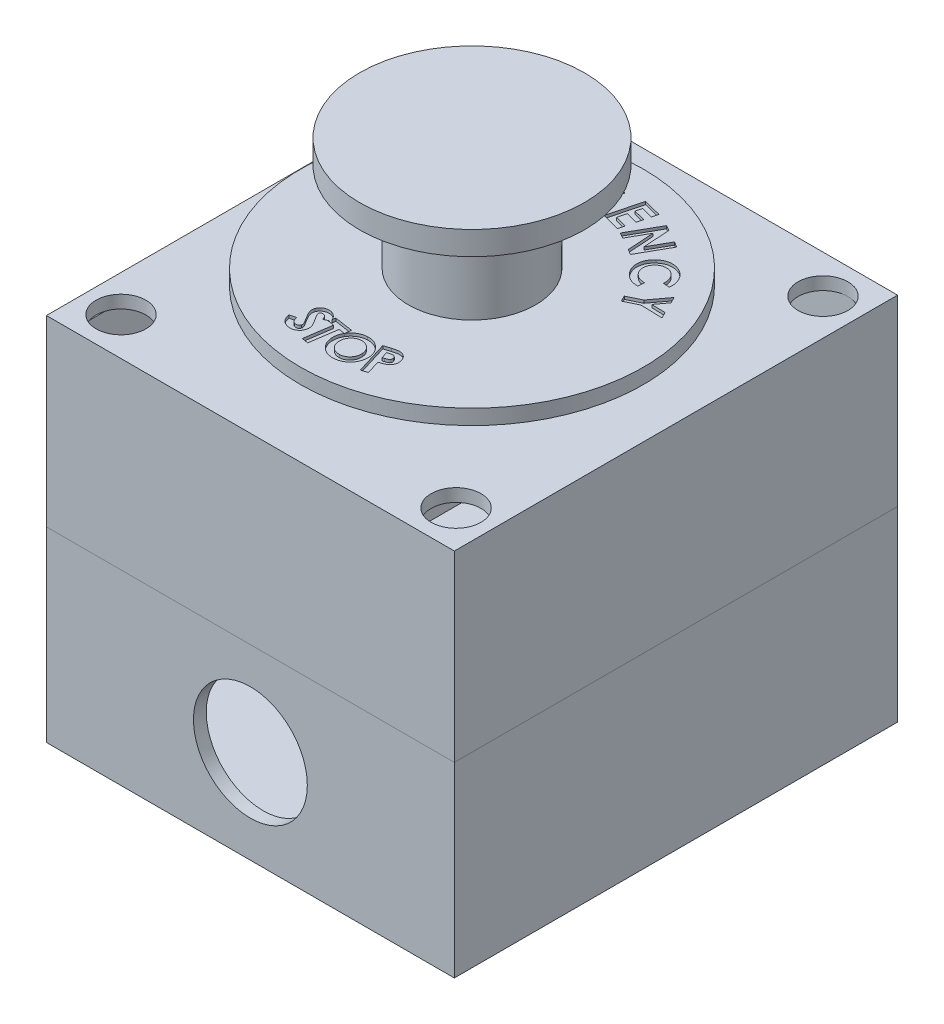
from build123d import *

# Parameters (mm, degrees)
SKETCH1_W           = 71.65
SKETCH1_H           = 77.85
BOSS_EXTRUDE1_DEPTH = 32.8
SHELL3_T            = -2.25
SKETCH2_W           = 71.65
SKETCH2_H           = 77.85
BOSS_EXTRUDE2_DEPTH = 32.15
SHELL4_T            = -2.25
SKETCH3_R           = 11.175
SKETCH3_R_2         = 4.375
CUT_EXTRUDE1_DEPTH  = 2.25
SKETCH4_R           = 30.125
SKETCH4_R_2         = 11.175
BOSS_EXTRUDE3_DEPTH = 2.65
CUT_EXTRUDE2_DEPTH  = 0.5
SKETCH6_R           = 11.175
BOSS_EXTRUDE4_DEPTH = 21.35
SKETCH7_R           = 19.75
BOSS_EXTRUDE5_DEPTH = 4.15
SKETCH8_R           = 10
CUT_EXTRUDE3_DEPTH  = 2.25


with BuildPart() as part:
    # Sketch1 → Boss-Extrude1 (new body)
    with BuildSketch(Plane(origin=(0, 0, 0), x_dir=(1, 0, 0), z_dir=(0, 1, 0))):
        Rectangle(SKETCH1_W, SKETCH1_H)
    extrude(amount=BOSS_EXTRUDE1_DEPTH)

    # Shell3
    shell3_openings = [part.faces().sort_by_distance(p)[0] for p in [
        (0, 32.8, 0),
    ]]
    offset(amount=SHELL3_T, openings=shell3_openings, kind=Kind.INTERSECTION)

    # Sketch8 → Cut-Extrude3 (cut)
    with BuildSketch(Plane.XY.offset(38.925)):
        with Locations((0, 16.4)):
            Circle(SKETCH8_R)
    extrude(amount=-CUT_EXTRUDE3_DEPTH, mode=Mode.SUBTRACT)


with BuildPart() as body_2:
    # Sketch2 → Boss-Extrude2 (new body)
    with BuildSketch(Plane(origin=(0, 32.8, 0), x_dir=(1, 0, 0), z_dir=(0, 1, 0))):
        Rectangle(SKETCH2_W, SKETCH2_H)
    extrude(amount=BOSS_EXTRUDE2_DEPTH)

    # Shell4
    shell4_openings = [body_2.faces().sort_by_distance(p)[0] for p in [
        (0, 32.8, 0),
    ]]
    offset(amount=SHELL4_T, openings=shell4_openings, kind=Kind.INTERSECTION)

    # Sketch3 → Cut-Extrude1 (cut)
    with BuildSketch(Plane(origin=(0, 64.95, 0), x_dir=(1, 0, 0), z_dir=(0, 1, 0))):
        with Locations(Location((0, 0, 0), (0, 0, 270))):
            Circle(SKETCH3_R)
        with Locations(Location((-29.425, 32.225, 0), (0, 0, 270))):
            Circle(SKETCH3_R_2)
        with Locations(Location((29.425, 32.225, 0), (0, 0, 270))):
            Circle(SKETCH3_R_2)
        with Locations(Location((29.425, -32.225, 0), (0, 0, 270))):
            Circle(SKETCH3_R_2)
        with Locations(Location((-29.425, -32.225, 0), (0, 0, 270))):
            Circle(SKETCH3_R_2)
    extrude(amount=-CUT_EXTRUDE1_DEPTH, mode=Mode.SUBTRACT)


with BuildPart() as body_3:
    # Sketch4 → Boss-Extrude3 (new body)
    with BuildSketch(Plane(origin=(0, 67.95, 0), x_dir=(1, 0, 0), z_dir=(0, 1, 0))):
        with Locations(Location((0, 0, 0), (0, 0, 270))):
            Circle(SKETCH4_R)
        with Locations(Location((0, 0, 0), (0, 0, 270))):
            Circle(SKETCH4_R_2, mode=Mode.SUBTRACT)
    extrude(amount=BOSS_EXTRUDE3_DEPTH)

    # Sketch5 → Cut-Extrude2 (cut)
    with BuildSketch(Plane(origin=(0, 70.6, 0), x_dir=(1, 0, 0), z_dir=(0, 1, 0))):
        Polygon((22.216736473, 13.295451936), (22.74678455, 12.19929809), (21.305678781, 10.270211551), (23.708323012, 10.210115397), (24.232361473, 9.127182705), (20.436688396, 9.225740397), (18.115774935, 8.103144243), (17.618178781, 9.130788474), (19.939092242, 10.253384628), align=None)
        with BuildLine():
            Line((20.220089869, 14.442296373), (19.121532177, 14.51921945))
            add(Edge.make_bspline(
                [(19.121532177, 14.51921945), (19.126635475, 14.615363019), (19.136592085, 14.802940543), (19.119361217, 15.078907871), (19.082129696, 15.341473275), (19.019601875, 15.591110902), (18.931427635, 15.826880028), (18.818536734, 16.048742483), (18.684399386, 16.259601178), (18.575486958, 16.385850104), (18.520570638, 16.449507911)],
                knots=[0, 0, 0, 0, 1.109559889, 2.164767739, 3.182852736, 4.164553532, 5.126637444, 6.07925455, 7.031512999, 8, 8, 8, 8], degree=3))
            add(Edge.make_bspline(
                [(18.520570638, 16.449507911), (18.471774653, 16.500108571), (18.375772324, 16.599661454), (18.218766209, 16.730949825), (18.054176946, 16.843691895), (17.881738472, 16.938325929), (17.700442301, 17.012544472), (17.511867375, 17.069964204), (17.315119658, 17.106514609), (17.113183165, 17.125829206), (16.910340069, 17.125856503), (16.710994634, 17.106916417), (16.518294194, 17.068005488), (16.330775871, 17.011809359), (16.150903719, 16.932830126), (15.976489909, 16.835590979), (15.807303581, 16.720806029), (15.703179532, 16.630113425), (15.650378331, 16.584123296)],
                knots=[0, 0, 0, 0, 1.052386963, 2.070489961, 3.059233594, 4.036767781, 5.010814159, 5.988569374, 6.98430004, 8.003039573, 9.023245161, 10.018089293, 10.997298366, 11.963567616, 12.94463228, 13.933211989, 14.951933846, 16, 16, 16, 16], degree=3))
            add(Edge.make_bspline(
                [(15.650378331, 16.584123296), (15.614772459, 16.550425515), (15.544161636, 16.48359867), (15.445533012, 16.37822406), (15.356762591, 16.268418899), (15.275705446, 16.156333236), (15.203039547, 16.041089621), (15.141306104, 15.921366187), (15.084864918, 15.800127811), (15.025165629, 15.634301379), (14.970140452, 15.422782004), (14.941211111, 15.162987386), (14.948496459, 14.900051837), (14.985648234, 14.681111095), (15.033805663, 14.508514966), (15.076445502, 14.380285781), (15.130089667, 14.256180426), (15.191648478, 14.134883873), (15.259876546, 14.015622412), (15.336971929, 13.899670568), (15.423978312, 13.788103053), (15.486573787, 13.716444458), (15.518166792, 13.680277142)],
                knots=[0, 0, 0, 0, 0.902655461, 1.790076806, 2.655418219, 3.501067431, 4.336289324, 5.161315006, 5.98011549, 6.797019175, 8.40390207, 9.992644644, 11.594234471, 13.232865513, 14.066946146, 14.89286202, 15.719206162, 16.553971738, 17.396784059, 18.248014752, 19.115743145, 20, 20, 20, 20], degree=3))
            add(Edge.make_bspline(
                [(15.518166792, 13.680277142), (15.574188779, 13.62162849), (15.684376753, 13.506274207), (15.868969892, 13.359092288), (16.060742087, 13.232056184), (16.231202828, 13.146752199), (16.375485639, 13.09057285), (16.492558234, 13.05384902), (16.617877505, 13.019708676), (16.75199737, 12.991510765), (16.894702439, 12.96715361), (17.046378113, 12.948606422), (17.206634234, 12.932518405), (17.316612751, 12.926259489), (17.3727341, 12.923065604)],
                knots=[0, 0, 0, 0, 1.412694756, 2.778587148, 4.105776388, 5.417860226, 6.092421986, 6.803777457, 7.556138486, 8.356275231, 9.192319846, 10.079560441, 11.020011728, 12, 12, 12, 12], degree=3))
            Line((17.3727341, 12.923065604), (17.299416792, 11.808882911))
            add(Edge.make_bspline(
                [(17.299416792, 11.808882911), (17.224052403, 11.813978196), (17.076727646, 11.823938625), (16.861505837, 11.847171838), (16.656350687, 11.875092153), (16.462405138, 11.912621306), (16.278796331, 11.956069163), (16.105880311, 12.004443997), (15.943858514, 12.061430356), (15.791118571, 12.125213671), (15.64554747, 12.198560491), (15.503496375, 12.279711572), (15.362120689, 12.367603892), (15.226134031, 12.469075351), (15.088899488, 12.57478649), (14.957592311, 12.69407974), (14.826037996, 12.819496243), (14.742108373, 12.90902991), (14.699657177, 12.954315604)],
                knots=[0, 0, 0, 0, 1.237979504, 2.42004258, 3.5474711, 4.630597417, 5.65636662, 6.639570284, 7.572081054, 8.469719187, 9.350749792, 10.241830455, 11.150925216, 12.07693919, 13.021511017, 13.988952338, 14.982821856, 16, 16, 16, 16], degree=3))
            add(Edge.make_bspline(
                [(14.699657177, 12.954315604), (14.62463575, 13.039891469), (14.477320626, 13.207931718), (14.28952194, 13.4784533), (14.129929181, 13.754157822), (14.001661711, 14.036918937), (13.906362221, 14.328049509), (13.84061445, 14.625117568), (13.808858351, 14.929839896), (13.806128317, 15.237829609), (13.834956878, 15.544678583), (13.893833945, 15.844406372), (13.983432231, 16.134366506), (14.102539843, 16.414830196), (14.254631547, 16.683634509), (14.434723817, 16.943513917), (14.645278351, 17.193512489), (14.805528186, 17.34639258), (14.887157177, 17.424267527)],
                knots=[0, 0, 0, 0, 1.087298607, 2.135063766, 3.142275972, 4.129746234, 5.097556959, 6.066004182, 7.032973177, 8.021238017, 9.006112165, 9.974407879, 10.93640254, 11.90257463, 12.881786517, 13.883748322, 14.922011451, 16, 16, 16, 16], degree=3))
            add(Edge.make_bspline(
                [(14.887157177, 17.424267527), (14.942148453, 17.473195034), (15.050803849, 17.569869237), (15.223984018, 17.698406476), (15.397879804, 17.817777497), (15.577288114, 17.921060621), (15.761172292, 18.010155872), (15.947923172, 18.087355124), (16.1392095, 18.150183128), (16.333662234, 18.199142128), (16.530724789, 18.23566275), (16.729620618, 18.25685616), (16.929571347, 18.265711297), (17.130824107, 18.259556693), (17.332750725, 18.238860994), (17.535773388, 18.204710835), (17.739963948, 18.158383515), (17.943484052, 18.096473094), (18.144569506, 18.02416079), (18.339681082, 17.938559644), (18.527115786, 17.841266599), (18.70720638, 17.732244133), (18.880533145, 17.612674935), (19.045014868, 17.479016895), (19.20487234, 17.337098636), (19.302983979, 17.23273649), (19.352301407, 17.180277142)],
                knots=[0, 0, 0, 0, 1.061507876, 2.097397393, 3.109068641, 4.103550453, 5.080796923, 6.0555098, 7.017037681, 7.983020916, 8.946770381, 9.90622827, 10.866660828, 11.832453788, 12.808554109, 13.793090768, 14.80132106, 15.827292257, 16.860468579, 17.882916222, 18.89900383, 19.905243602, 20.918680406, 21.934307502, 22.961645706, 24, 24, 24, 24], degree=3))
            add(Edge.make_bspline(
                [(19.352301407, 17.180277142), (19.392785422, 17.134160342), (19.473563148, 17.042143522), (19.58694232, 16.898048597), (19.690058645, 16.747378541), (19.785280353, 16.591595297), (19.873330556, 16.43120615), (19.951143958, 16.264126326), (20.022604349, 16.092923023), (20.083186535, 15.915965487), (20.136336203, 15.736941354), (20.178462143, 15.555459804), (20.210644534, 15.373286803), (20.234172487, 15.189627869), (20.245578336, 15.004570184), (20.248393268, 14.818024397), (20.239970264, 14.630213437), (20.22673856, 14.505142332), (20.220089869, 14.442296373)],
                knots=[0, 0, 0, 0, 0.994048471, 1.983424239, 2.96821208, 3.950022362, 4.940440777, 5.930518856, 6.934560982, 7.94446007, 8.959061906, 9.958794142, 10.960799264, 11.955038424, 12.95668612, 13.962802997, 14.976345499, 16, 16, 16, 16], degree=3))
        make_face()
        Polygon((10.608315809, 23.562697309), (11.555431193, 23.02784154), (11.849902347, 18.349956924), (13.782594655, 21.767024232), (14.771777347, 21.208130001), (11.834277347, 16.014620386), (10.884758116, 16.551880001), (10.587883116, 21.217745386), (8.659998501, 17.810293463), (7.670815809, 18.369187693), align=None)
        Polygon((5.081720858, 25.415085868), (8.247586243, 24.596576252), (7.968740089, 23.516047406), (5.899028551, 24.052105098), (5.627393935, 23.002826252), (7.697105474, 22.46676856), (7.423067012, 21.405470483), (5.353355474, 21.941528175), (4.957922781, 20.415085868), (7.02763432, 19.879028175), (6.747586243, 18.79489356), (3.581720858, 19.613403175), align=None)
        with BuildLine():
            Line((2.002101237, 24.751845655), (1.225658929, 23.939345655))
            add(Edge.make_bspline(
                [(1.225658929, 23.939345655), (1.160739613, 24.001604367), (1.033255163, 24.123864089), (0.825246849, 24.280759616), (0.611752878, 24.414598564), (0.390255387, 24.522426248), (0.161430287, 24.604826973), (-0.075025273, 24.659516896), (-0.317852068, 24.69253828), (-0.482168717, 24.692812731), (-0.565206456, 24.692951424)],
                knots=[0, 0, 0, 0, 1.078351845, 2.117599175, 3.119307423, 4.097454024, 5.067464779, 6.030507225, 7.004712988, 8, 8, 8, 8], degree=3))
            add(Edge.make_bspline(
                [(-0.565206456, 24.692951424), (-0.637035056, 24.688975864), (-0.778149644, 24.681165471), (-0.98516717, 24.648461385), (-1.182547393, 24.59709373), (-1.370064154, 24.526248765), (-1.549362866, 24.440238789), (-1.71761614, 24.333235115), (-1.877853746, 24.210281339), (-2.024990446, 24.069088447), (-2.158935652, 23.91626784), (-2.276474172, 23.754991109), (-2.374183878, 23.585537788), (-2.454249977, 23.409463561), (-2.514813703, 23.225306863), (-2.555271175, 23.033876998), (-2.577567055, 22.834923752), (-2.577340832, 22.700217486), (-2.577225686, 22.631653348)],
                knots=[0, 0, 0, 0, 1.074817449, 2.111588153, 3.12694921, 4.118071934, 5.103733486, 6.09404167, 7.093075841, 8.118192181, 9.136780168, 10.127468555, 11.096117737, 12.055671245, 13.013953079, 13.987698506, 14.975758707, 16, 16, 16, 16], degree=3))
            add(Edge.make_bspline(
                [(-2.577225686, 22.631653348), (-2.573475283, 22.560989046), (-2.566080931, 22.421666241), (-2.529982031, 22.218127095), (-2.477626758, 22.022386073), (-2.403601117, 21.836271889), (-2.312316866, 21.658092111), (-2.199901649, 21.490498042), (-2.071539082, 21.329336632), (-1.922990832, 21.181124619), (-1.76169303, 21.045391459), (-1.58964326, 20.927739467), (-1.409889664, 20.827698183), (-1.220170805, 20.750031431), (-1.023484881, 20.687802207), (-0.81708956, 20.647372654), (-0.602968248, 20.625380789), (-0.457483815, 20.625555265), (-0.383716071, 20.625643732)],
                knots=[0, 0, 0, 0, 1.024221376, 2.019370362, 2.988020267, 3.954738387, 4.915146988, 5.882544282, 6.873215482, 7.895066353, 8.916801852, 9.922907492, 10.909951126, 11.890764485, 12.887519874, 13.89367573, 14.931990273, 16, 16, 16, 16], degree=3))
            add(Edge.make_bspline(
                [(-0.383716071, 20.625643732), (-0.335599675, 20.627900207), (-0.241156795, 20.632329218), (-0.102702126, 20.64818423), (0.029745559, 20.670939954), (0.156480802, 20.700562045), (0.276817628, 20.739339536), (0.391314851, 20.785024592), (0.500203498, 20.83776717), (0.602378002, 20.899453423), (0.699813424, 20.968714755), (0.791682823, 21.046107236), (0.877953227, 21.133033325), (0.959725159, 21.227376636), (1.035009707, 21.332002853), (1.108227089, 21.443110553), (1.172005316, 21.565362421), (1.211554362, 21.649937518), (1.231668544, 21.692951424)],
                knots=[0, 0, 0, 0, 1.120714692, 2.199739221, 3.240504075, 4.246831093, 5.225747871, 6.179704807, 7.113725497, 8.037922487, 8.953757669, 9.893253267, 10.829412051, 11.801243693, 12.795185344, 13.827058911, 14.894867548, 16, 16, 16, 16], degree=3))
            Line((1.231668544, 21.692951424), (-0.49669684, 21.644874501))
            Line((-0.49669684, 21.644874501), (-0.526744917, 22.712182194))
            Line((-0.526744917, 22.712182194), (2.475658929, 22.796316809))
            Line((2.475658929, 22.796316809), (2.491283929, 22.545114886))
            add(Edge.make_bspline(
                [(2.491283929, 22.545114886), (2.491725712, 22.480191545), (2.492604845, 22.350996252), (2.478930803, 22.157820961), (2.452901069, 21.966983575), (2.412365817, 21.778515471), (2.361173768, 21.591950716), (2.29563997, 21.407397538), (2.217725416, 21.225157116), (2.127573072, 21.046887288), (2.028535214, 20.874446966), (1.920566809, 20.710744008), (1.803786315, 20.558006783), (1.679474005, 20.415719691), (1.548142171, 20.28288012), (1.40876859, 20.159874642), (1.260283245, 20.04833566), (1.105260841, 19.94582477), (0.942857074, 19.854068057), (0.772572701, 19.774986163), (0.59577333, 19.70584084), (0.410584126, 19.650093549), (0.219153921, 19.602318661), (0.019300653, 19.569563096), (-0.186915185, 19.54621621), (-0.327165876, 19.539898483), (-0.398139148, 19.536701424)],
                knots=[0, 0, 0, 0, 1.004147739, 1.998220677, 2.993143514, 3.981479951, 4.9785051, 5.984182096, 7.008857228, 8.042807654, 9.073016962, 10.083857123, 11.074387429, 12.045231887, 13.005092057, 13.9625276, 14.91831651, 15.875872428, 16.836132773, 17.801102652, 18.778356565, 19.770437119, 20.791205421, 21.828550206, 22.901146976, 24, 24, 24, 24], degree=3))
            add(Edge.make_bspline(
                [(-0.398139148, 19.536701424), (-0.47468068, 19.535714086), (-0.625890273, 19.533763576), (-0.84978901, 19.548013344), (-1.067461484, 19.572397256), (-1.279396391, 19.611377369), (-1.485296303, 19.662870584), (-1.685877601, 19.726479096), (-1.879559494, 19.803864985), (-2.067168888, 19.892713177), (-2.247578066, 19.993157201), (-2.417919841, 20.106734485), (-2.580395277, 20.229597642), (-2.732795508, 20.364831605), (-2.877492317, 20.509726729), (-3.01104892, 20.667236347), (-3.136197208, 20.834665595), (-3.252678757, 21.011591327), (-3.356323706, 21.197122796), (-3.44797662, 21.387325638), (-3.5267091, 21.581519526), (-3.590969879, 21.780193607), (-3.644953849, 21.982115628), (-3.68235448, 22.188831272), (-3.710345715, 22.39897535), (-3.716139946, 22.541019413), (-3.719052609, 22.612422578)],
                knots=[0, 0, 0, 0, 1.088999131, 2.151343354, 3.190249436, 4.204567505, 5.215418359, 6.208947955, 7.196767941, 8.181209007, 9.161414191, 10.132355917, 11.09252403, 12.057976134, 13.029603973, 14.004238299, 14.994030836, 16.002950311, 17.01638665, 18.016032339, 19.005972659, 19.995830881, 20.986001042, 21.97789331, 22.983520927, 24, 24, 24, 24], degree=3))
            add(Edge.make_bspline(
                [(-3.719052609, 22.612422578), (-3.719213978, 22.709850725), (-3.719532193, 22.901976767), (-3.689497467, 23.185545607), (-3.637252857, 23.460670895), (-3.557551653, 23.726173197), (-3.453034564, 23.982972568), (-3.325484296, 24.231153353), (-3.172828451, 24.470848914), (-3.052674258, 24.619136011), (-2.991889148, 24.694153348)],
                knots=[0, 0, 0, 0, 1.035478945, 2.041940428, 3.027109918, 4.009807164, 4.984556678, 5.971631463, 6.97386349, 8, 8, 8, 8], degree=3))
            add(Edge.make_bspline(
                [(-2.991889148, 24.694153348), (-2.954380824, 24.7379282), (-2.879809177, 24.824958555), (-2.759126755, 24.945507957), (-2.634964243, 25.059206734), (-2.506624703, 25.164795585), (-2.37353562, 25.262843737), (-2.236196987, 25.352889256), (-2.092632063, 25.433453914), (-1.946109791, 25.508380172), (-1.793751194, 25.572626328), (-1.638174516, 25.631286609), (-1.47710511, 25.680286999), (-1.311216211, 25.720657023), (-1.141319505, 25.754844312), (-0.966769566, 25.779872651), (-0.787437802, 25.79672252), (-0.666199936, 25.802040227), (-0.604869917, 25.804730271)],
                knots=[0, 0, 0, 0, 1.017680996, 2.023288138, 3.009898991, 3.99009594, 4.95661266, 5.928011526, 6.888084382, 7.86264738, 8.832550635, 9.806394246, 10.797864034, 11.803446286, 12.820536837, 13.857151809, 14.916007658, 16, 16, 16, 16], degree=3))
            add(Edge.make_bspline(
                [(-0.604869917, 25.804730271), (-0.540361746, 25.805815435), (-0.412486541, 25.807966568), (-0.221906752, 25.799141872), (-0.03424326, 25.780963333), (0.150633784, 25.754488368), (0.333099236, 25.720259237), (0.511680948, 25.673852889), (0.68792714, 25.620158273), (0.802784745, 25.577355984), (0.860274314, 25.555932194)],
                knots=[0, 0, 0, 0, 1.034683742, 2.051064099, 3.058219287, 4.057945443, 5.046078613, 6.034274475, 7.016097248, 8, 8, 8, 8], degree=3))
            add(Edge.make_bspline(
                [(0.860274314, 25.555932194), (0.908634743, 25.535720208), (1.006772592, 25.494704012), (1.150945774, 25.420523039), (1.295187018, 25.336595018), (1.43836837, 25.241343199), (1.580399474, 25.134938009), (1.722644385, 25.018140156), (1.863933016, 24.889859317), (1.955594823, 24.798300045), (2.002101237, 24.751845655)],
                knots=[0, 0, 0, 0, 0.89389203, 1.813975655, 2.763519178, 3.739795132, 4.745905524, 5.789956038, 6.878690904, 8, 8, 8, 8], degree=3))
        make_face()
        with BuildLine():
            Line((-9.813180429, 23.918278999), (-8.674959275, 24.300490537))
            add(Edge.make_bspline(
                [(-8.674959275, 24.300490537), (-8.599773658, 24.325354459), (-8.454776552, 24.373305074), (-8.24348218, 24.43562611), (-8.047186177, 24.487722501), (-7.866531752, 24.52920125), (-7.700331662, 24.557901624), (-7.549672051, 24.578427337), (-7.41342006, 24.585472476), (-7.290446691, 24.58365338), (-7.176165975, 24.571571771), (-7.066815942, 24.549041434), (-6.959349906, 24.521257849), (-6.855360205, 24.481534067), (-6.753322941, 24.435357701), (-6.654201723, 24.378979719), (-6.556863961, 24.315920799), (-6.463493886, 24.243230669), (-6.372767468, 24.164557636), (-6.289244381, 24.076467294), (-6.211015906, 23.982500041), (-6.137777055, 23.882522925), (-6.073705019, 23.773360745), (-6.013241649, 23.658712747), (-5.960354494, 23.536233729), (-5.92973102, 23.451697339), (-5.914141968, 23.408663614)],
                knots=[0, 0, 0, 0, 1.706699695, 3.291407649, 4.74706766, 6.083599819, 7.284612418, 8.38136156, 9.358493001, 10.222167383, 11.029853103, 11.830864387, 12.626833115, 13.419187092, 14.226734324, 15.038609625, 15.874468565, 16.724217417, 17.5868984, 18.460231229, 19.336972531, 20.221334869, 21.127641506, 22.062299829, 23.013602843, 24, 24, 24, 24], degree=3))
            add(Edge.make_bspline(
                [(-5.914141968, 23.408663614), (-5.899413264, 23.363189865), (-5.870483681, 23.27387199), (-5.839851467, 23.138645638), (-5.81761709, 23.006682889), (-5.806571958, 22.877235667), (-5.806747169, 22.751019816), (-5.816342841, 22.6276449), (-5.835377074, 22.5069105), (-5.865298502, 22.388912559), (-5.906978236, 22.274294244), (-5.956979951, 22.162012833), (-6.019248363, 22.053688847), (-6.090295948, 21.947337539), (-6.17204424, 21.843804789), (-6.265484547, 21.744429396), (-6.367258025, 21.646152923), (-6.442091604, 21.585979464), (-6.480247737, 21.55529823)],
                knots=[0, 0, 0, 0, 1.098116678, 2.156880632, 3.183274718, 4.172051075, 5.13893139, 6.081071029, 7.013621671, 7.944943986, 8.874078597, 9.813739925, 10.766307077, 11.741917866, 12.751486045, 13.794028029, 14.875219364, 16, 16, 16, 16], degree=3))
            Line((-6.480247737, 21.55529823), (-4.303565045, 19.497605922))
            Line((-4.303565045, 19.497605922), (-5.475440045, 19.103375153))
            Line((-5.475440045, 19.103375153), (-7.547555429, 21.063711691))
            Line((-7.547555429, 21.063711691), (-7.646113122, 21.030057845))
            Line((-7.646113122, 21.030057845), (-6.843228506, 18.643038614))
            Line((-6.843228506, 18.643038614), (-7.916545814, 18.282461691))
            Line((-7.916545814, 18.282461691), (-9.813180429, 23.918278999))
        make_face()
        with BuildLine():
            Line((-7.998276583, 22.075730922), (-7.661738122, 22.188711691))
            add(Edge.make_bspline(
                [(-7.661738122, 22.188711691), (-7.620758426, 22.202816223), (-7.541858907, 22.22997213), (-7.430203717, 22.27412652), (-7.33049858, 22.319840526), (-7.241916302, 22.365410608), (-7.164596569, 22.412149372), (-7.098610448, 22.459909288), (-7.043279945, 22.507809243), (-6.987129102, 22.573783719), (-6.935695028, 22.665189122), (-6.909717877, 22.79076001), (-6.915386868, 22.928745296), (-6.942060377, 23.020859532), (-6.956209275, 23.069721307)],
                knots=[0, 0, 0, 0, 1.200100227, 2.310591374, 3.323395071, 4.236488305, 5.068016154, 5.822553005, 6.490556281, 7.088654339, 8.215868703, 9.351894237, 10.595318698, 12, 12, 12, 12], degree=3))
            add(Edge.make_bspline(
                [(-6.956209275, 23.069721307), (-6.967468365, 23.098903446), (-6.989595761, 23.156254865), (-7.035000575, 23.234717642), (-7.092029012, 23.302392469), (-7.157534308, 23.359856522), (-7.231303832, 23.405502431), (-7.310605, 23.439848546), (-7.394934828, 23.461460297), (-7.46968695, 23.468601844), (-7.534481815, 23.466948665), (-7.591490328, 23.460556195), (-7.65588422, 23.449206569), (-7.728398124, 23.435509282), (-7.807646096, 23.413725137), (-7.895876691, 23.390576269), (-7.991211694, 23.359818718), (-8.057580159, 23.338169288), (-8.092026583, 23.326932845)],
                knots=[0, 0, 0, 0, 1.125783416, 2.212492938, 3.247358765, 4.300976577, 5.338255151, 6.359749009, 7.402935197, 8.461385918, 9.053319855, 9.735504325, 10.525643538, 11.408780708, 12.392459036, 13.484904222, 14.694620176, 16, 16, 16, 16], degree=3))
            Line((-8.092026583, 23.326932845), (-8.386497737, 23.228375153))
            Line((-8.386497737, 23.228375153), (-7.998276583, 22.075730922))
        make_face(mode=Mode.SUBTRACT)
        Polygon((-14.843161555, 21.223502481), (-12.06792117, 22.937444789), (-11.482584632, 21.990329404), (-13.297488478, 20.870137097), (-12.731382708, 19.951867866), (-10.916478862, 21.072060174), (-10.340757708, 20.141771712), (-12.155661555, 19.021579404), (-11.331142324, 17.685040943), (-9.516238478, 18.805233251), (-8.928498093, 17.854512097), (-11.703738478, 16.140569789), align=None)
        Polygon((-20.838053985, 15.102481307), (-20.103678985, 15.935413999), (-16.070025139, 14.219067845), (-18.265938601, 18.019548614), (-17.541178985, 18.841663999), (-12.402957831, 15.65055823), (-13.126515524, 14.829644768), (-16.376515524, 16.840462076), (-14.389736677, 13.39695246), (-15.051996293, 12.644548614), (-18.708246293, 14.196231307), (-16.312813601, 11.215462076), (-17.044784754, 10.38493323), align=None)
        Polygon((-24.111150579, 9.395241297), (-22.76379481, 12.350770143), (-21.755381348, 11.891635527), (-22.636390963, 9.95894322), (-21.656823656, 9.511827835), (-20.77581404, 11.444520143), (-19.785429425, 10.993798989), (-20.66643904, 9.061106681), (-19.242160194, 8.41206822), (-18.361150579, 10.344760527), (-17.349131348, 9.883222066), (-18.696487117, 6.92769322), align=None)
        with BuildLine():
            Line((-4.296925782, -20.435179715), (-5.319762321, -20.891910484))
            add(Edge.make_bspline(
                [(-5.319762321, -20.891910484), (-5.339794774, -20.834718615), (-5.378267803, -20.724879619), (-5.446546871, -20.571242842), (-5.522608731, -20.436622809), (-5.602218297, -20.318156511), (-5.691269996, -20.220007837), (-5.784787876, -20.138301665), (-5.885768372, -20.075014954), (-5.958243622, -20.048189279), (-5.994041167, -20.03493933)],
                knots=[0, 0, 0, 0, 1.285377933, 2.468613521, 3.560882849, 4.562940946, 5.489787149, 6.363796067, 7.191833279, 8, 8, 8, 8], degree=3))
            add(Edge.make_bspline(
                [(-5.994041167, -20.03493933), (-6.028280367, -20.025775266), (-6.094402704, -20.008077734), (-6.194457546, -20.001045853), (-6.290030083, -20.009885245), (-6.377550827, -20.037910893), (-6.455016717, -20.077131022), (-6.518581816, -20.126308655), (-6.567248581, -20.185746029), (-6.584944943, -20.231829548), (-6.593800782, -20.254891253)],
                knots=[0, 0, 0, 0, 1.202950169, 2.32312309, 3.391387234, 4.447154586, 5.428193202, 6.330380111, 7.16446742, 8, 8, 8, 8], degree=3))
            add(Edge.make_bspline(
                [(-6.593800782, -20.254891253), (-6.600522547, -20.278766013), (-6.614011959, -20.326678503), (-6.614079817, -20.402546853), (-6.607469809, -20.480414397), (-6.590487358, -20.530763308), (-6.581781552, -20.556573945)],
                knots=[0, 0, 0, 0, 0.963640143, 1.933858111, 2.940822353, 4, 4, 4, 4], degree=3))
            add(Edge.make_bspline(
                [(-6.581781552, -20.556573945), (-6.573132777, -20.577080288), (-6.553062633, -20.624666824), (-6.51429697, -20.703757237), (-6.46211875, -20.799476512), (-6.398194271, -20.912980728), (-6.32106993, -21.04389606), (-6.230974066, -21.192328469), (-6.128959577, -21.358545606), (-6.055506083, -21.474146239), (-6.016877705, -21.53493933)],
                knots=[0, 0, 0, 0, 0.472302808, 1.096014782, 1.868328227, 2.785947846, 3.86077978, 5.0930698, 6.471277633, 8, 8, 8, 8], degree=3))
            add(Edge.make_bspline(
                [(-6.016877705, -21.53493933), (-5.980649212, -21.591322016), (-5.911729308, -21.698582596), (-5.816537978, -21.852485596), (-5.730291382, -21.988537597), (-5.656586154, -22.108179926), (-5.592910971, -22.210455563), (-5.543572082, -22.297096802), (-5.502479186, -22.365400377), (-5.481446633, -22.406637935), (-5.472406552, -22.424362407)],
                knots=[0, 0, 0, 0, 1.541982731, 2.933417593, 4.163629296, 5.248251996, 6.166797445, 6.935180536, 7.542325879, 8, 8, 8, 8], degree=3))
            add(Edge.make_bspline(
                [(-5.472406552, -22.424362407), (-5.437695759, -22.494792534), (-5.371235898, -22.62964328), (-5.292204542, -22.831656883), (-5.236271227, -23.022659682), (-5.20207165, -23.205117447), (-5.192014393, -23.382623908), (-5.19860117, -23.559131138), (-5.226478687, -23.737366146), (-5.259630721, -23.854146318), (-5.27649309, -23.913545099)],
                knots=[0, 0, 0, 0, 1.218525502, 2.33307934, 3.36252957, 4.30432348, 5.207883106, 6.116693177, 7.042079426, 8, 8, 8, 8], degree=3))
            add(Edge.make_bspline(
                [(-5.27649309, -23.913545099), (-5.295895066, -23.970035848), (-5.333995876, -24.080970082), (-5.407946835, -24.238103128), (-5.494677606, -24.383245507), (-5.59463888, -24.515808639), (-5.707416422, -24.635954098), (-5.833207131, -24.743507922), (-5.972144149, -24.838332987), (-6.121525277, -24.921198129), (-6.279925292, -24.988208585), (-6.444202372, -25.039066513), (-6.613369716, -25.072697261), (-6.787298381, -25.089866068), (-6.966066606, -25.088039868), (-7.14935898, -25.069509743), (-7.337857691, -25.035231996), (-7.462683131, -24.998452374), (-7.52649309, -24.979650868)],
                knots=[0, 0, 0, 0, 1.025866792, 2.014555478, 2.978063652, 3.926822306, 4.86201884, 5.804461055, 6.765062118, 7.748101039, 8.735326297, 9.71532257, 10.698313268, 11.694429613, 12.713434653, 13.765039949, 14.857502839, 16, 16, 16, 16], degree=3))
            add(Edge.make_bspline(
                [(-7.52649309, -24.979650868), (-7.575985893, -24.963013753), (-7.673659805, -24.930180451), (-7.81451889, -24.871376235), (-7.946880489, -24.803899348), (-8.071252455, -24.728986195), (-8.188475275, -24.647114703), (-8.29820528, -24.557102946), (-8.399033322, -24.457789151), (-8.493496859, -24.352060825), (-8.579616534, -24.236689259), (-8.657156429, -24.11162083), (-8.728175436, -23.977879664), (-8.792288792, -23.835056555), (-8.848612178, -23.682890239), (-8.895951701, -23.520722826), (-8.939119393, -23.350230448), (-8.959563664, -23.23221724), (-8.970002705, -23.171958561)],
                knots=[0, 0, 0, 0, 1.020671388, 2.014292243, 2.981184668, 3.922904415, 4.850840233, 5.774567553, 6.694100479, 7.615233522, 8.544259766, 9.504944814, 10.489632949, 11.502913207, 12.563676934, 13.65910204, 14.804714995, 16, 16, 16, 16], degree=3))
            Line((-8.970002705, -23.171958561), (-7.888271936, -22.907535484))
            add(Edge.make_bspline(
                [(-7.888271936, -22.907535484), (-7.872946571, -22.977522027), (-7.843577339, -23.11164288), (-7.783961451, -23.299964859), (-7.711760778, -23.465940083), (-7.62924084, -23.610194509), (-7.535245951, -23.732886878), (-7.427859901, -23.831170186), (-7.310452509, -23.909894448), (-7.223598014, -23.942017192), (-7.180339244, -23.958016253)],
                knots=[0, 0, 0, 0, 1.292402024, 2.476734176, 3.558013536, 4.55249833, 5.469376559, 6.334062821, 7.170262938, 8, 8, 8, 8], degree=3))
            add(Edge.make_bspline(
                [(-7.180339244, -23.958016253), (-7.134985804, -23.970674805), (-7.046985035, -23.995236609), (-6.912382214, -24.000769283), (-6.782549025, -23.987914458), (-6.661072224, -23.947433367), (-6.552706185, -23.88979191), (-6.462046954, -23.817174909), (-6.394443566, -23.728032662), (-6.367935922, -23.660310233), (-6.35461809, -23.626285484)],
                knots=[0, 0, 0, 0, 1.143074275, 2.217944563, 3.25879758, 4.304805511, 5.313232734, 6.235208882, 7.113342864, 8, 8, 8, 8], degree=3))
            add(Edge.make_bspline(
                [(-6.35461809, -23.626285484), (-6.34600783, -23.593643056), (-6.328369848, -23.526775562), (-6.32832435, -23.420161768), (-6.342952739, -23.308573264), (-6.370395249, -23.211639844), (-6.403655902, -23.127111027), (-6.43760881, -23.052625985), (-6.479933213, -22.96856585), (-6.530418571, -22.874540235), (-6.591060393, -22.771033933), (-6.660466262, -22.657940393), (-6.737755473, -22.534250673), (-6.793160341, -22.449500474), (-6.822166167, -22.405131638)],
                knots=[0, 0, 0, 0, 0.898865416, 1.841311532, 2.824069737, 3.902117162, 4.52246803, 5.250848677, 6.088792242, 7.037300727, 8.102403626, 9.294139053, 10.583414537, 12, 12, 12, 12], degree=3))
            add(Edge.make_bspline(
                [(-6.822166167, -22.405131638), (-6.876986948, -22.320809102), (-6.982410605, -22.158651798), (-7.128727099, -21.922011974), (-7.259051839, -21.703111516), (-7.37266538, -21.501628618), (-7.467459894, -21.316497897), (-7.546504731, -21.149277163), (-7.608172834, -20.999326323), (-7.65446662, -20.864134322), (-7.685974822, -20.738463743), (-7.70912801, -20.618098766), (-7.723640803, -20.500431992), (-7.729693949, -20.385184536), (-7.727962487, -20.272571692), (-7.715095805, -20.16304242), (-7.696541154, -20.055933423), (-7.67694566, -19.986719126), (-7.66711809, -19.952006638)],
                knots=[0, 0, 0, 0, 1.800807953, 3.463061899, 4.98122829, 6.362220552, 7.603837687, 8.704609012, 9.67307466, 10.505616779, 11.260723643, 11.990919517, 12.699185361, 13.381622773, 14.05609593, 14.712825329, 15.354453659, 16, 16, 16, 16], degree=3))
            add(Edge.make_bspline(
                [(-7.66711809, -19.952006638), (-7.650479529, -19.903931591), (-7.617652975, -19.809083355), (-7.551768744, -19.675198041), (-7.474857046, -19.550168459), (-7.383916893, -19.435803621), (-7.281645768, -19.330568405), (-7.165811663, -19.236226377), (-7.038207245, -19.151036228), (-6.899722406, -19.075446121), (-6.753198382, -19.014216415), (-6.603146886, -18.964938643), (-6.450388725, -18.932645235), (-6.294977015, -18.915973181), (-6.137590061, -18.913221055), (-5.97748554, -18.927121392), (-5.81511861, -18.955308185), (-5.708128275, -18.986617379), (-5.653896936, -19.002487407)],
                knots=[0, 0, 0, 0, 0.985086998, 1.943498129, 2.885029142, 3.824797736, 4.769173694, 5.723550718, 6.714130129, 7.739046685, 8.775892836, 9.787518406, 10.795621947, 11.795378773, 12.812620154, 13.841059779, 14.905674801, 16, 16, 16, 16], degree=3))
            add(Edge.make_bspline(
                [(-5.653896936, -19.002487407), (-5.584266248, -19.026805884), (-5.445866973, -19.075141748), (-5.250857102, -19.178395911), (-5.068490579, -19.303349747), (-4.929149101, -19.428185098), (-4.821495044, -19.539450457), (-4.743018733, -19.635584864), (-4.66549251, -19.742530284), (-4.589286247, -19.859899587), (-4.512976608, -19.987918302), (-4.439078703, -20.126829859), (-4.366625307, -20.277013392), (-4.320647229, -20.381349591), (-4.296925782, -20.435179715)],
                knots=[0, 0, 0, 0, 1.297690966, 2.579315141, 3.873316093, 5.18325105, 5.867107249, 6.599055733, 7.367002241, 8.193069486, 9.063328101, 9.991606341, 10.963810455, 12, 12, 12, 12], degree=3))
        make_face()
        Polygon((-4.379435776, -19.545462232), (-1.112608852, -20.028635309), (-1.277272314, -21.138010309), (-2.354195391, -20.97815454), (-3.063330006, -25.781039155), (-4.203955006, -25.612769925), (-3.494820391, -20.809885309), (-4.544099237, -20.654837232), align=None)
        with BuildLine():
            add(Edge.make_bspline(
                [(1.206124277, -19.597185228), (1.309906575, -19.593540913), (1.514971685, -19.586340052), (1.819162547, -19.611155886), (2.113828417, -19.665438986), (2.399318043, -19.748400589), (2.674492873, -19.862470924), (2.94072043, -20.005275853), (3.197044055, -20.178222304), (3.4413415, -20.377250693), (3.66695364, -20.598170897), (3.869207385, -20.834976647), (4.041641602, -21.088249112), (4.188421903, -21.354498373), (4.305067274, -21.636153785), (4.393894907, -21.931759981), (4.458138646, -22.2410364), (4.475945553, -22.453464803), (4.48497043, -22.561127536)],
                knots=[0, 0, 0, 0, 1.013323856, 2.002242892, 2.972863591, 3.934741636, 4.899503046, 5.87612026, 6.87973968, 7.914116526, 8.948730065, 9.959036505, 10.949702681, 11.935351069, 12.922674887, 13.920130271, 14.945882672, 16, 16, 16, 16], degree=3))
            add(Edge.make_bspline(
                [(4.48497043, -22.561127536), (4.489206331, -22.668122919), (4.49754691, -22.8787991), (4.471414357, -23.190693746), (4.420809143, -23.491950228), (4.340036888, -23.782682011), (4.228178638, -24.061161286), (4.089751812, -24.330056994), (3.919859905, -24.586278809), (3.725450199, -24.829909052), (3.509732497, -25.053973625), (3.278179169, -25.254155818), (3.031488969, -25.425100425), (2.772287877, -25.571188268), (2.497491808, -25.686027113), (2.210093138, -25.776012114), (1.908167052, -25.836399541), (1.701559612, -25.85471889), (1.596749277, -25.864012152)],
                knots=[0, 0, 0, 0, 1.051002637, 2.069446514, 3.067806827, 4.048478746, 5.027063556, 6.011046754, 7.014205118, 8.04189204, 9.068975904, 10.065317254, 11.043545862, 12.012587154, 12.982587023, 13.963503729, 14.966901393, 16, 16, 16, 16], degree=3))
            add(Edge.make_bspline(
                [(1.596749277, -25.864012152), (1.486958828, -25.868187743), (1.271099417, -25.876397389), (0.952543828, -25.851314911), (0.646424308, -25.7975753), (0.352667553, -25.713028588), (0.070984878, -25.598249389), (-0.197833828, -25.453128074), (-0.454788007, -25.278849342), (-0.694553699, -25.075552485), (-0.915785897, -24.852322598), (-1.112579386, -24.614018871), (-1.282037841, -24.362412831), (-1.424482364, -24.098469394), (-1.539367499, -23.82181367), (-1.625678351, -23.532536052), (-1.687155679, -23.230784784), (-1.705329409, -23.024133295), (-1.7145488, -22.919300613)],
                knots=[0, 0, 0, 0, 1.067416679, 2.098651912, 3.09956168, 4.084543021, 5.064621834, 6.050988436, 7.049211722, 8.077559409, 9.102138157, 10.101067913, 11.077657593, 12.046613071, 13.012282762, 13.984520725, 14.977563151, 16, 16, 16, 16], degree=3))
            add(Edge.make_bspline(
                [(-1.7145488, -22.919300613), (-1.71734801, -22.848403528), (-1.722883223, -22.708210259), (-1.717214721, -22.498926615), (-1.69588903, -22.293564721), (-1.66467912, -22.091218434), (-1.616284984, -21.893372895), (-1.558453283, -21.69803534), (-1.484080736, -21.507118635), (-1.39935047, -21.319732546), (-1.302129572, -21.138662579), (-1.194084428, -20.965630874), (-1.075372965, -20.801228111), (-0.947217441, -20.644810857), (-0.807500518, -20.498111666), (-0.657342058, -20.360969576), (-0.499054162, -20.230371736), (-0.329847823, -20.11108377), (-0.153648454, -20.001904594), (0.027658862, -19.904471527), (0.213430473, -19.819791231), (0.403488737, -19.749030832), (0.597756414, -19.690801758), (0.796713909, -19.646923203), (0.999695981, -19.613428027), (1.137101826, -19.602616256), (1.206124277, -19.597185228)],
                knots=[0, 0, 0, 0, 1.038519072, 2.053587716, 3.061446588, 4.05941038, 5.048093486, 6.040734952, 7.039542863, 8.044787399, 9.049775262, 10.045720611, 11.028873726, 12.016373197, 13.003715904, 13.991615881, 14.991903585, 16.005734578, 17.019718239, 18.024706102, 19.016844968, 20.006015042, 20.991352459, 21.983109873, 22.98686479, 24, 24, 24, 24], degree=3))
        make_face()
        with BuildLine():
            add(Edge.make_bspline(
                [(1.261412738, -20.708964075), (1.193920242, -20.714806771), (1.060778471, -20.726332598), (0.866894998, -20.767047692), (0.68205343, -20.82334995), (0.506539969, -20.896850483), (0.340841322, -20.988690842), (0.185322687, -21.099269297), (0.03781693, -21.225795316), (-0.098168083, -21.369269517), (-0.219764367, -21.525696595), (-0.325695955, -21.691456973), (-0.412672417, -21.866771001), (-0.480804939, -22.051024578), (-0.53239775, -22.243648763), (-0.562143, -22.445206483), (-0.578193848, -22.65509011), (-0.57217942, -22.797492399), (-0.569116108, -22.870021767)],
                knots=[0, 0, 0, 0, 1.02630534, 2.024582275, 2.996795121, 3.95231835, 4.903953035, 5.862868208, 6.840587242, 7.845972062, 8.854453114, 9.840233429, 10.82359667, 11.815347395, 12.814270912, 13.840881783, 14.900302228, 16, 16, 16, 16], degree=3))
            add(Edge.make_bspline(
                [(-0.569116108, -22.870021767), (-0.562531311, -22.950403797), (-0.549652852, -23.107613909), (-0.49986181, -23.334488105), (-0.432262026, -23.547819794), (-0.340733858, -23.74605973), (-0.230786495, -23.931929554), (-0.094910562, -24.100360682), (0.058753297, -24.257758685), (0.176461568, -24.347390222), (0.236172354, -24.392858305)],
                knots=[0, 0, 0, 0, 1.083610724, 2.119311518, 3.116171311, 4.087898372, 5.049895604, 6.012616937, 6.991844805, 8, 8, 8, 8], degree=3))
            add(Edge.make_bspline(
                [(0.236172354, -24.392858305), (0.284419195, -24.426334628), (0.379837873, -24.492541375), (0.532737371, -24.573114072), (0.687792809, -24.643258277), (0.848571085, -24.695254464), (1.012726796, -24.73568758), (1.181268779, -24.760977206), (1.35429575, -24.770515727), (1.470551366, -24.766358442), (1.529441584, -24.764252536)],
                knots=[0, 0, 0, 0, 1.025401634, 2.027955949, 3.015481569, 3.996406591, 4.976331434, 5.967598492, 6.97047064, 8, 8, 8, 8], degree=3))
            add(Edge.make_bspline(
                [(1.529441584, -24.764252536), (1.595310503, -24.758266568), (1.725540441, -24.746431666), (1.915681294, -24.707595621), (2.097735544, -24.651336476), (2.269403254, -24.574667113), (2.433929086, -24.48281239), (2.589069348, -24.371930268), (2.734698101, -24.24212375), (2.871074737, -24.097676343), (2.993847396, -23.940357991), (3.100347173, -23.773857904), (3.188451677, -23.599906913), (3.259125993, -23.418596282), (3.309022599, -23.229339138), (3.341609929, -23.0330132), (3.356561355, -22.829336384), (3.351649155, -22.69134244), (3.349153123, -22.62122369)],
                knots=[0, 0, 0, 0, 1.013202887, 2.003211077, 2.968550279, 3.928188203, 4.879596702, 5.852640685, 6.844589808, 7.865524137, 8.893746741, 9.89887736, 10.890351116, 11.877994603, 12.876065113, 13.884660516, 14.92513428, 16, 16, 16, 16], degree=3))
            add(Edge.make_bspline(
                [(3.349153123, -22.62122369), (3.343308773, -22.551733788), (3.331777513, -22.414625953), (3.291070472, -22.214755219), (3.234766053, -22.023946308), (3.161377186, -21.842402396), (3.069152131, -21.670596997), (2.959407938, -21.508100193), (2.832558468, -21.354774045), (2.689983597, -21.212952996), (2.53668137, -21.083620615), (2.373831796, -20.972753794), (2.204587869, -20.880234655), (2.028142189, -20.80833772), (1.845937383, -20.753537742), (1.656956659, -20.718779568), (1.461178294, -20.70277387), (1.328734685, -20.706877946), (1.261412738, -20.708964075)],
                knots=[0, 0, 0, 0, 1.061212181, 2.093836659, 3.099579146, 4.087546576, 5.070205921, 6.063528024, 7.06891883, 8.095704885, 9.122182734, 10.118927935, 11.090845846, 12.053914313, 13.01524184, 13.983341333, 14.9749193, 16, 16, 16, 16], degree=3))
        make_face(mode=Mode.SUBTRACT)
        with BuildLine():
            Line((3.940858391, -19.616572424), (5.089896852, -19.262005116))
            add(Edge.make_bspline(
                [(5.089896852, -19.262005116), (5.165126377, -19.239656792), (5.309948008, -19.196634843), (5.520887198, -19.139440548), (5.717334406, -19.093717507), (5.899413943, -19.058749481), (6.066491736, -19.032782566), (6.219397862, -19.017819147), (6.357953981, -19.014042762), (6.48382976, -19.019404529), (6.600630867, -19.035944017), (6.71212766, -19.059342394), (6.819779336, -19.092835708), (6.925001677, -19.13157494), (7.025572443, -19.181769143), (7.124163618, -19.238247666), (7.218245588, -19.304309801), (7.309179311, -19.378058637), (7.394825092, -19.459492551), (7.476621673, -19.547103428), (7.548917808, -19.644311523), (7.618633913, -19.746518874), (7.68030651, -19.857164745), (7.737163609, -19.974220562), (7.787921436, -20.098239438), (7.816001229, -20.184488507), (7.830281468, -20.22835127)],
                knots=[0, 0, 0, 0, 1.688933715, 3.251305049, 4.702822589, 6.028581246, 7.240679464, 8.340586999, 9.332487091, 10.221628206, 11.048378989, 11.868584455, 12.670503299, 13.472792887, 14.278734412, 15.08619654, 15.916178232, 16.749735138, 17.603646109, 18.457992283, 19.325421563, 20.207848283, 21.119040639, 22.048409359, 23.007500483, 24, 24, 24, 24], degree=3))
            add(Edge.make_bspline(
                [(7.830281468, -20.22835127), (7.844122172, -20.277063931), (7.871364669, -20.372944488), (7.900890739, -20.517032738), (7.915374266, -20.658300377), (7.923076567, -20.796076812), (7.914860045, -20.930792296), (7.897450574, -21.062426528), (7.867054094, -21.190803377), (7.824734808, -21.315147333), (7.773363115, -21.435577046), (7.71140814, -21.550334282), (7.640714874, -21.660020654), (7.559372712, -21.763377371), (7.47021416, -21.862571088), (7.371509068, -21.956359496), (7.263326244, -22.044294501), (7.18565167, -22.097093907), (7.146387237, -22.123783963)],
                knots=[0, 0, 0, 0, 1.115030842, 2.194702124, 3.233291588, 4.240028063, 5.229569431, 6.200289412, 7.16113652, 8.12924698, 9.089607911, 10.040888847, 10.997717609, 11.959536333, 12.934017723, 13.932486052, 14.954873411, 16, 16, 16, 16], degree=3))
            add(Edge.make_bspline(
                [(7.146387237, -22.123783963), (7.119665031, -22.139619136), (7.061797953, -22.173910287), (6.965232842, -22.224708106), (6.85098014, -22.275760027), (6.719341741, -22.328031158), (6.571707952, -22.384724262), (6.4071285, -22.443606731), (6.225353757, -22.503366157), (6.098364255, -22.543025736), (6.032204545, -22.563687809)],
                knots=[0, 0, 0, 0, 0.62085217, 1.344458681, 2.179572426, 3.120936991, 4.17544642, 5.34067572, 6.614530177, 8, 8, 8, 8], degree=3))
            Line((6.032204545, -22.563687809), (6.773791083, -24.973543578))
            Line((6.773791083, -24.973543578), (5.690858391, -25.307678193))
            Line((5.690858391, -25.307678193), (3.940858391, -19.616572424))
        make_face()
        with BuildLine():
            Line((5.707685314, -21.507197424), (6.051435314, -21.401428193))
            add(Edge.make_bspline(
                [(6.051435314, -21.401428193), (6.113713622, -21.381543495), (6.2283025, -21.344956674), (6.382738179, -21.287230792), (6.503489251, -21.230274063), (6.595576344, -21.174819573), (6.66412719, -21.115356948), (6.71777132, -21.050588498), (6.760249365, -20.979328443), (6.790438806, -20.901680637), (6.80825828, -20.818993227), (6.815176629, -20.732205986), (6.804283553, -20.641926965), (6.788917907, -20.582355534), (6.781002622, -20.551668578)],
                knots=[0, 0, 0, 0, 1.831434125, 3.36974439, 4.614721882, 5.56768447, 6.371183345, 7.144320325, 7.914273475, 8.68545273, 9.46701652, 10.277073404, 11.112471, 12, 12, 12, 12], degree=3))
            add(Edge.make_bspline(
                [(6.781002622, -20.551668578), (6.771935024, -20.525410817), (6.754264054, -20.474239586), (6.719349678, -20.403118965), (6.678346507, -20.340028319), (6.631175381, -20.284765749), (6.576142866, -20.239120661), (6.515889652, -20.200138908), (6.448891729, -20.169843533), (6.401391846, -20.156057999), (6.377156468, -20.149024347)],
                knots=[0, 0, 0, 0, 1.112362007, 2.167775581, 3.165186105, 4.121167983, 5.066713508, 6.019725233, 6.989624713, 8, 8, 8, 8], degree=3))
            add(Edge.make_bspline(
                [(6.377156468, -20.149024347), (6.357597683, -20.144862894), (6.315630205, -20.135933624), (6.24692063, -20.133928412), (6.16978361, -20.135902003), (6.083969229, -20.146509496), (5.989338528, -20.162089905), (5.885424189, -20.18393854), (5.772713077, -20.212713221), (5.695170748, -20.236434304), (5.654800699, -20.248783963)],
                knots=[0, 0, 0, 0, 0.650512827, 1.395811787, 2.231889996, 3.164828137, 4.210231735, 5.357496422, 6.62426107, 8, 8, 8, 8], degree=3))
            Line((5.654800699, -20.248783963), (5.349512237, -20.342533963))
            Line((5.349512237, -20.342533963), (5.707685314, -21.507197424))
        make_face(mode=Mode.SUBTRACT)
    extrude(amount=-CUT_EXTRUDE2_DEPTH, mode=Mode.SUBTRACT)

    # Sketch6 → Boss-Extrude4 (add)
    with BuildSketch(Plane(origin=(0, 64.95, 0), x_dir=(1, 0, 0), z_dir=(0, 1, 0))):
        with Locations(Location((0, 0, 0), (0, 0, 90))):
            Circle(SKETCH6_R)
    extrude(amount=BOSS_EXTRUDE4_DEPTH)

    # Sketch7 → Boss-Extrude5 (add)
    with BuildSketch(Plane(origin=(0, 86.3, 0), x_dir=(1, 0, 0), z_dir=(0, 1, 0))):
        with Locations(Location((0, 0, 0), (0, 0, 90))):
            Circle(SKETCH7_R)
    extrude(amount=BOSS_EXTRUDE5_DEPTH)


solid = Compound([part.part, body_2.part, body_3.part])
